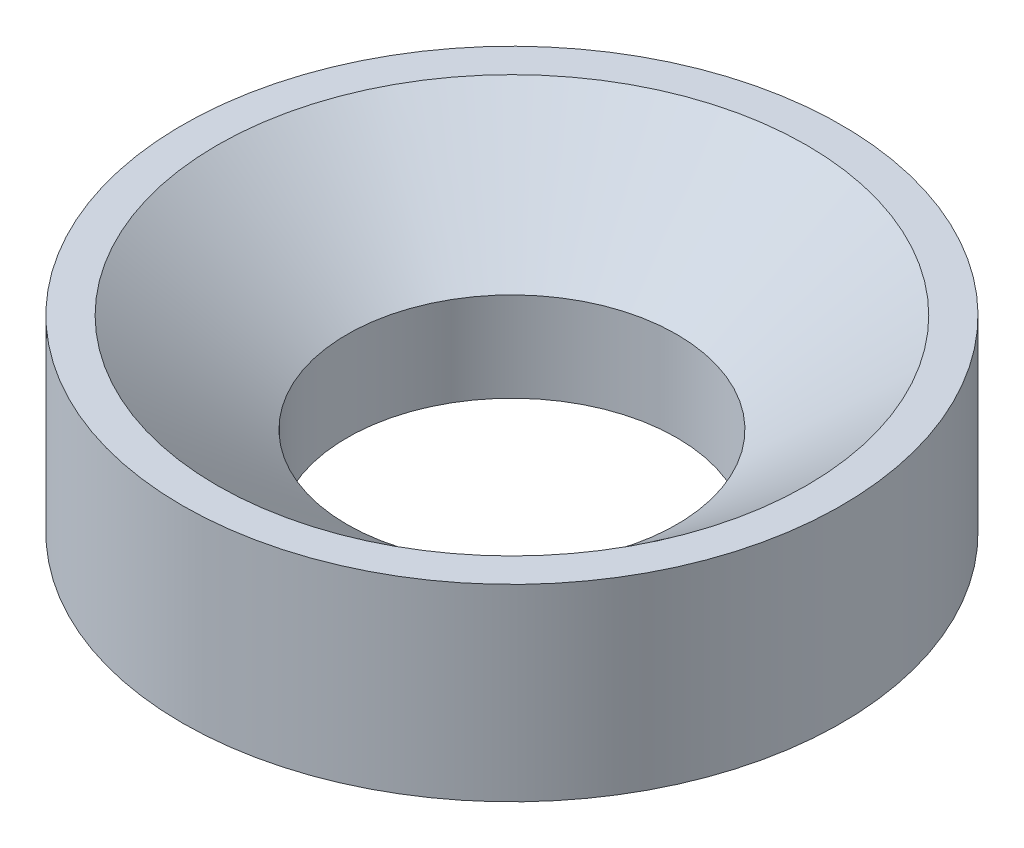
from build123d import *


with BuildPart() as part:
    # Sketch2 → Revolve1 (revolve)
    with BuildSketch(Plane.XY):
        Polygon((44.45, 0), (44.45, 24.136240786), (79.507616708, 50.8), (88.9, 50.8), (88.9, 0), align=None)
    revolve(axis=Axis((0, 44.668427518, 0), (0, -1, 0)))


solid = part.part
